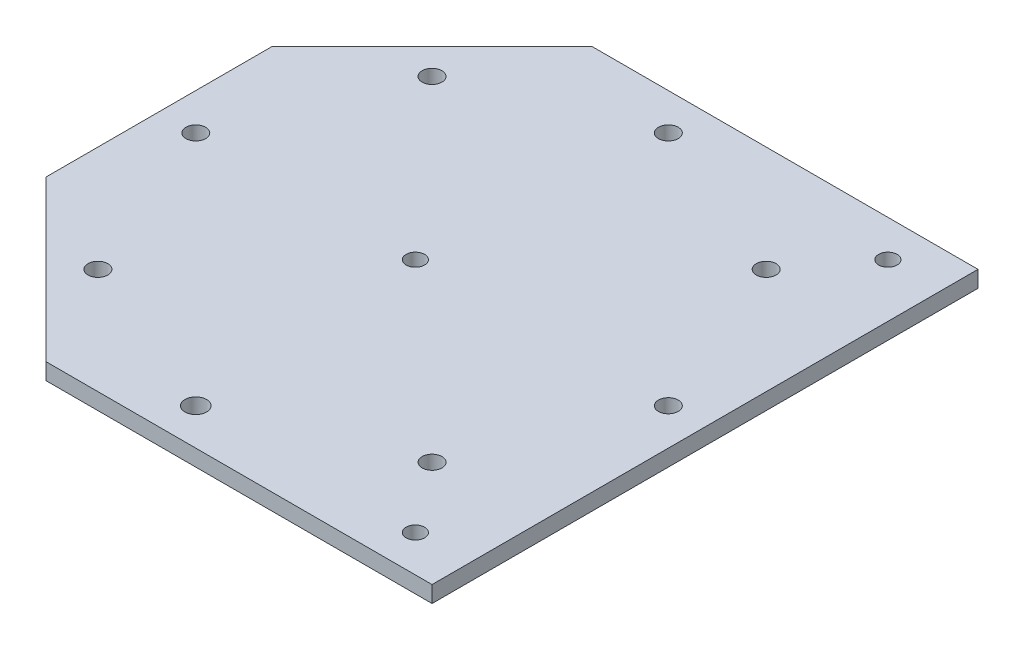
from build123d import *

# Parameters (mm, degrees)
SKETCH1_R           = 3.951125178
SKETCH1_R_2         = 3.606945722
SKETCH1_R_3         = 3.375000002
SKETCH1_R_4         = 3.375000001
SKETCH1_R_5         = 3.374999999
BOSS_EXTRUDE1_DEPTH = 6


with BuildPart() as part:
    # Sketch1 → Boss-Extrude1 (new body)
    with BuildSketch(Plane(origin=(0, 0, 0), x_dir=(1, 0, 0), z_dir=(0, 1, 0))):
        Polygon((-41.199524293, 99.465227688), (99.465250609, 99.465227688), (99.465250609, -99.465227688), (-41.199524293, -99.465227688), (-99.465227688, -41.199524293), (-99.465227688, 41.199524293), align=None)
        with Locations((0, -86.090250609)):
            Circle(SKETCH1_R, mode=Mode.SUBTRACT)
        with Locations((-86.090250609, 0)):
            Circle(SKETCH1_R_2, mode=Mode.SUBTRACT)
        with Locations((-60.875, 60.875)):
            Circle(SKETCH1_R_2, mode=Mode.SUBTRACT)
        with Locations((0, 86.090250609)):
            Circle(SKETCH1_R_2, mode=Mode.SUBTRACT)
        with Locations((60.875, 60.875)):
            Circle(SKETCH1_R_2, mode=Mode.SUBTRACT)
        with Locations((86.090250609, 0)):
            Circle(SKETCH1_R_2, mode=Mode.SUBTRACT)
        with Locations((60.875, -60.875)):
            Circle(SKETCH1_R_2, mode=Mode.SUBTRACT)
        with Locations((-60.875, -60.875)):
            Circle(SKETCH1_R_2, mode=Mode.SUBTRACT)
        with Locations((80.004750061, -86.090249939)):
            Circle(SKETCH1_R_3, mode=Mode.SUBTRACT)
        with Locations((-6.085500548, 6.7e-07)):
            Circle(SKETCH1_R_4, mode=Mode.SUBTRACT)
        with Locations((80.004750061, 86.09025128)):
            Circle(SKETCH1_R_5, mode=Mode.SUBTRACT)
    extrude(amount=BOSS_EXTRUDE1_DEPTH)


solid = part.part
